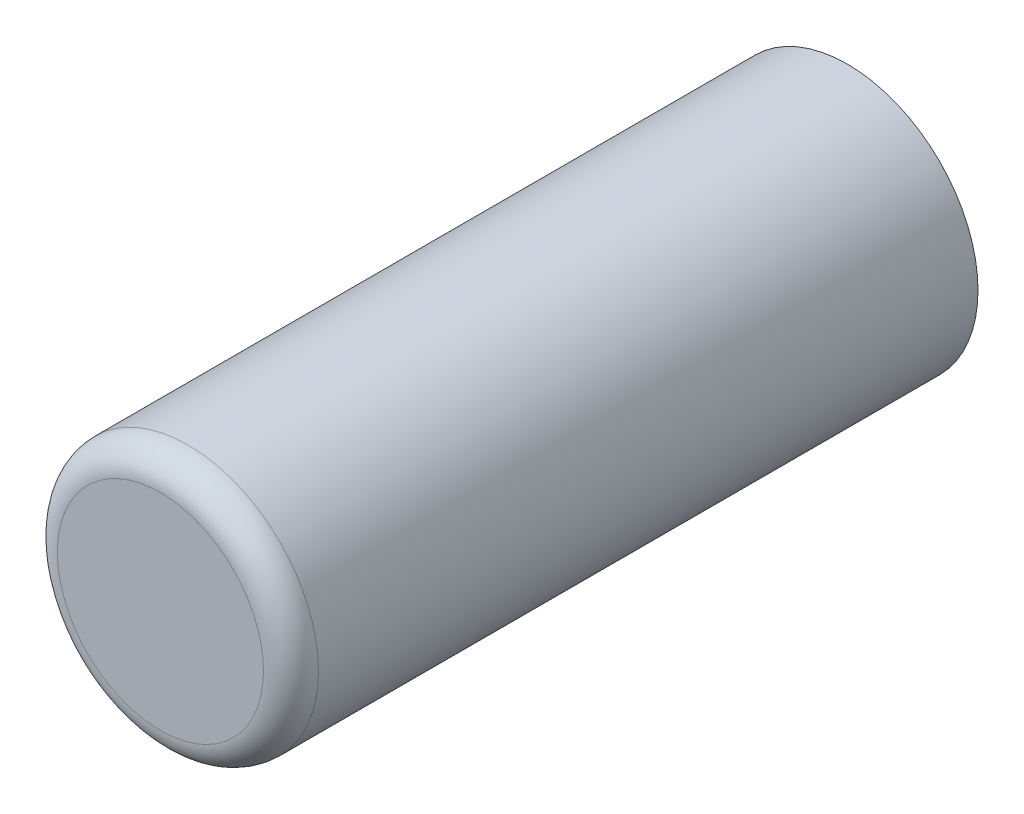
from build123d import *

# Parameters (mm, degrees)
SKETCH1_R           = 3.8
BOSS_EXTRUDE1_DEPTH = 10
FILLET1_R           = 0.8


with BuildPart() as part:
    # Sketch1 → Boss-Extrude1 (new body, symmetric)
    with BuildSketch(Plane.XY):
        Circle(SKETCH1_R)
    extrude(amount=BOSS_EXTRUDE1_DEPTH, both=True)

    # Fillet1
    fillet1_edges = [part.edges().sort_by_distance(p)[0] for p in [
        (-3.8, 0, 10),
    ]]
    fillet(fillet1_edges, radius=FILLET1_R)


solid = part.part
